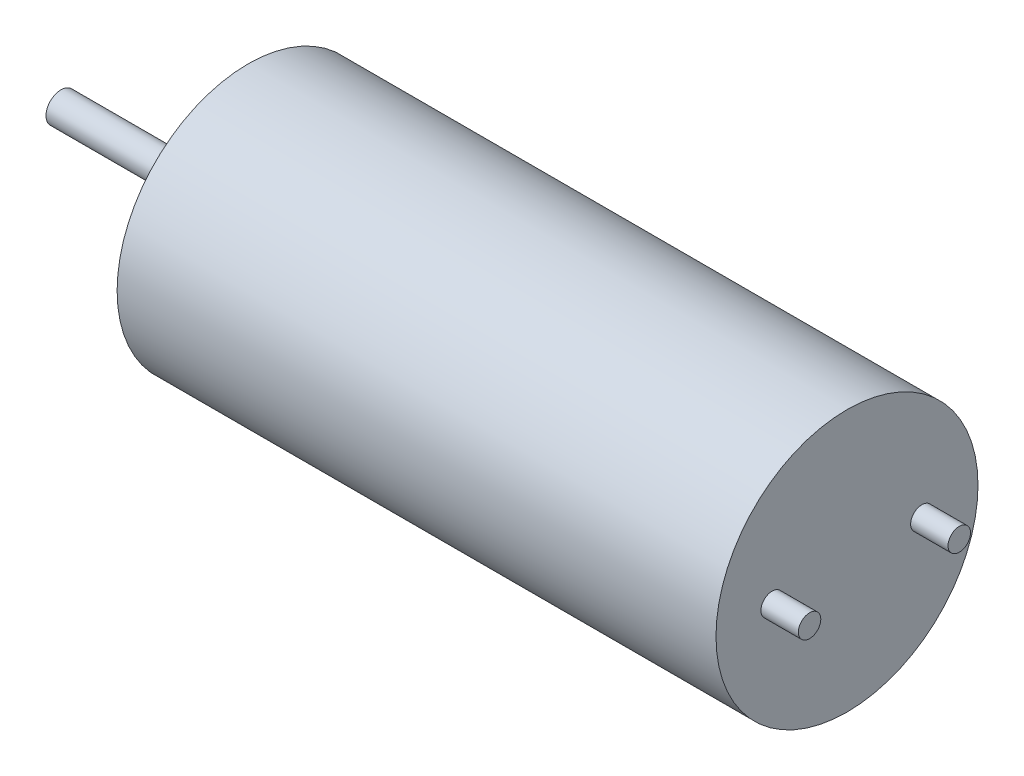
from build123d import *

# Parameters (mm, degrees)
SKETCH1_R           = 3.5
BOSS_EXTRUDE1_DEPTH = 16
SKETCH2_R           = 1.2
BOSS_EXTRUDE2_DEPTH = 0.8
SKETCH3_R           = 0.4
BOSS_EXTRUDE3_DEPTH = 4.2
SKETCH4_R           = 0.3
BOSS_EXTRUDE4_DEPTH = 1


with BuildPart() as part:
    # Sketch1 → Boss-Extrude1 (new body)
    with BuildSketch(Plane(origin=(0, 0, 0), x_dir=(0, 0, -1), z_dir=(1, 0, 0))):
        Circle(SKETCH1_R)
    extrude(amount=BOSS_EXTRUDE1_DEPTH)

    # Sketch2 → Boss-Extrude2 (add)
    with BuildSketch(Plane.ZY):
        Circle(SKETCH2_R)
    extrude(amount=BOSS_EXTRUDE2_DEPTH)

    # Sketch3 → Boss-Extrude3 (add)
    with BuildSketch(Plane.ZY.offset(0.8)):
        Circle(SKETCH3_R)
    extrude(amount=BOSS_EXTRUDE3_DEPTH)

    # Sketch4 → Boss-Extrude4 (add)
    with BuildSketch(Plane(origin=(16, 0, 0), x_dir=(0, 0, -1), z_dir=(1, 0, 0))):
        with Locations((-2, 0)):
            Circle(SKETCH4_R)
        with Locations((2, 0)):
            Circle(SKETCH4_R)
    extrude(amount=BOSS_EXTRUDE4_DEPTH)


solid = part.part
